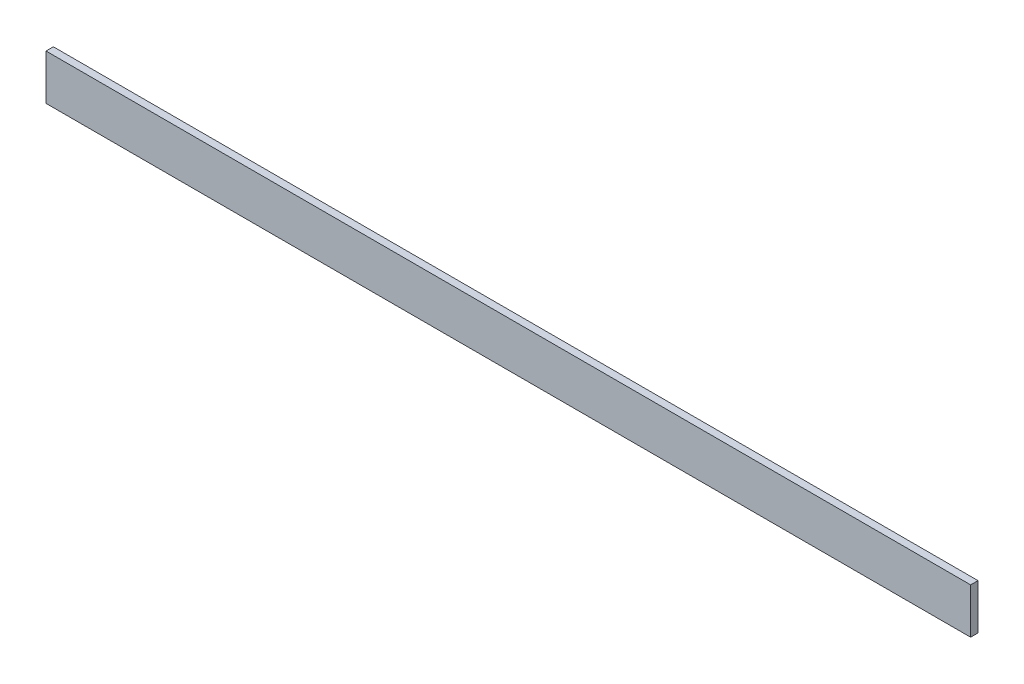
from build123d import *

# Parameters (mm, degrees)
SKETCH1_W           = 4787.9
SKETCH1_H           = 234.95
BOSS_EXTRUDE1_DEPTH = 38.1


with BuildPart() as part:
    # Sketch1 → Boss-Extrude1 (new body)
    with BuildSketch(Plane.XY):
        with Locations((2393.95, 117.475)):
            Rectangle(SKETCH1_W, SKETCH1_H)
    extrude(amount=BOSS_EXTRUDE1_DEPTH)


solid = part.part
